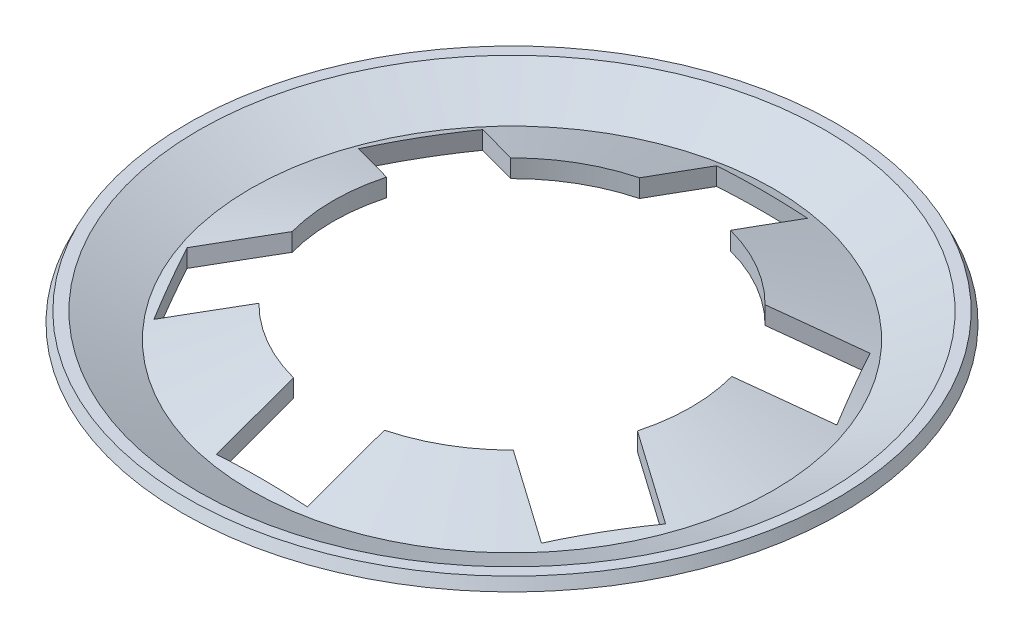
from build123d import *

# Parameters (mm, degrees)
SKETCH3_W         = 2.032
SKETCH3_H         = 5.588
EXTRUDE1_DEPTH    = 11.473781034
CIRPATTERN1_COUNT = 6


with BuildPart() as part:
    # Sketch2 → Revolve1 (revolve)
    with BuildSketch(Plane.XY):
        Polygon((-4, 1.088262662), (-5.8419953, 0.40140039), (-7.003246048, 0.951561432), (-7.257246048, 0.951561432), (-7.3659953, 0.722019279), (-5.8419953, 0), (-4, 0.686862271), align=None)
    revolve(axis=Axis((0, 0, 0), (0, 1, 0)))

    # Sketch3 → Extrude1 (cut, through all)
    with BuildSketch(Plane(origin=(0, 0, 0), x_dir=(1, 0, 0), z_dir=(0, 1, 0))):
        with Locations((0, 2.794)):
            Rectangle(SKETCH3_W, SKETCH3_H)
    extrude1 = extrude(amount=EXTRUDE1_DEPTH, mode=Mode.SUBTRACT)

    # CirPattern1: Extrude1 ×6 about axis
    cirpattern1_axis = Axis((0, 1.088262662, 0), (0, -1, 0))
    for i in range(1, CIRPATTERN1_COUNT):
        add(extrude1.rotate(cirpattern1_axis, i * 360 / CIRPATTERN1_COUNT), mode=Mode.SUBTRACT)


solid = part.part
